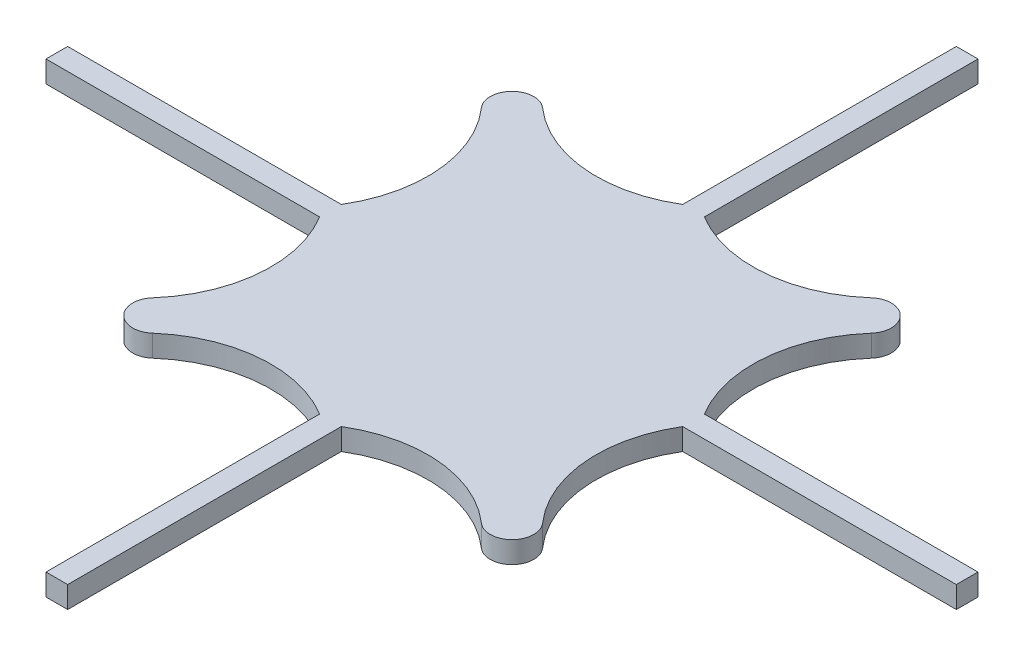
from build123d import *

# Parameters (mm, degrees)
BOSS_EXTRUDE1_DEPTH = 2


with BuildPart() as part:
    # Sketch1 → Boss-Extrude1 (new body)
    with BuildSketch(Plane(origin=(0, 0, 0), x_dir=(1, 0, 0), z_dir=(0, 1, 0))):
        with BuildLine():
            Line((-65.26908877, -1.246266978), (-65.26908877, -3.246266978))
            Line((-65.26908877, -3.246266978), (-40.019014758, -3.246266978))
            ThreePointArc((-40.019014758, -3.246266978), (-38.315467936, -10.540153027), (-41.26908877, -17.423391323))
            ThreePointArc((-41.26908877, -17.423391323), (-41.183302332, -20.160480541), (-38.446213114, -20.246266978))
            ThreePointArc((-38.446213114, -20.246266978), (-31.562974818, -17.292646145), (-24.26908877, -18.996192966))
            Line((-24.26908877, -18.996192966), (-24.26908877, -44.246266978))
            Line((-24.26908877, -44.246266978), (-22.26908877, -44.246266978))
            Line((-22.26908877, -44.246266978), (-22.26908877, -18.996192966))
            ThreePointArc((-22.26908877, -18.996192966), (-14.975202721, -17.292646145), (-8.091964425, -20.246266978))
            ThreePointArc((-8.091964425, -20.246266978), (-5.354875207, -20.160480541), (-5.26908877, -17.423391323))
            ThreePointArc((-5.26908877, -17.423391323), (-8.222709603, -10.540153027), (-6.519162781, -3.246266978))
            Line((-6.519162781, -3.246266978), (18.73091123, -3.246266978))
            Line((18.73091123, -3.246266978), (18.73091123, -1.246266978))
            Line((18.73091123, -1.246266978), (-6.519162781, -1.246266978))
            ThreePointArc((-6.519162781, -1.246266978), (-8.222709603, 6.04761907), (-5.26908877, 12.930857366))
            ThreePointArc((-5.26908877, 12.930857366), (-5.354875207, 15.667946584), (-8.091964425, 15.753733022))
            ThreePointArc((-8.091964425, 15.753733022), (-14.975202721, 12.800112188), (-22.26908877, 14.50365901))
            Line((-22.26908877, 14.50365901), (-22.26908877, 39.753733022))
            Line((-22.26908877, 39.753733022), (-24.26908877, 39.753733022))
            Line((-24.26908877, 39.753733022), (-24.26908877, 14.50365901))
            ThreePointArc((-24.26908877, 14.50365901), (-31.562974818, 12.800112188), (-38.446213114, 15.753733022))
            ThreePointArc((-38.446213114, 15.753733022), (-41.183302332, 15.667946584), (-41.26908877, 12.930857366))
            ThreePointArc((-41.26908877, 12.930857366), (-38.315467936, 6.04761907), (-40.019014758, -1.246266978))
            Line((-40.019014758, -1.246266978), (-65.26908877, -1.246266978))
        make_face()
    extrude(amount=BOSS_EXTRUDE1_DEPTH)


solid = part.part
